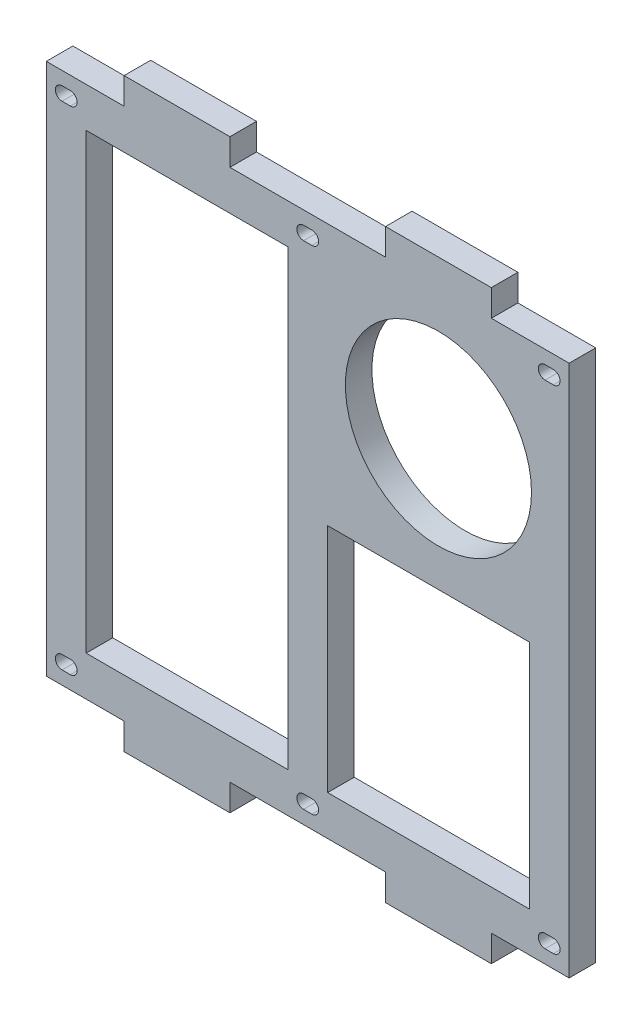
from build123d import *

# Parameters (mm, degrees)
CROQUIS1_W              = 250
CROQUIS1_H              = 280
CROQUIS1_R              = 44.5
CROQUIS1_W_2            = 96.425
CROQUIS1_H_2            = 216.5
CROQUIS1_H_3            = 110.55
SALIENTE_EXTRUIR1_DEPTH = 12.7
CROQUIS2_W              = 37.2
CROQUIS2_H              = 12.7
CROQUIS2_W_2            = 74.4
CORTAR_EXTRUIR1_DEPTH   = 13.7


with BuildPart() as part:
    # Croquis1 → Saliente-Extruir1 (new body)
    with BuildSketch(Plane.XY):
        Rectangle(CROQUIS1_W, CROQUIS1_H)
        with Locations((62.5, 64.8)):
            Circle(CROQUIS1_R, mode=Mode.SUBTRACT)
        with Locations((-57.7375, 0)):
            Rectangle(CROQUIS1_W_2, CROQUIS1_H_2, mode=Mode.SUBTRACT)
        with Locations((57.7375, -52.975)):
            Rectangle(CROQUIS1_W_2, CROQUIS1_H_3, mode=Mode.SUBTRACT)
    extrude(amount=SALIENTE_EXTRUIR1_DEPTH)

    # Croquis2 → Cortar-Extruir1 (cut, through all)
    with BuildSketch(Plane.XY.offset(12.7)):
        with Locations((-106.4, 133.65)):
            Rectangle(CROQUIS2_W, CROQUIS2_H)
        with Locations((0, 133.65)):
            Rectangle(CROQUIS2_W_2, CROQUIS2_H)
        with Locations((106.4, 133.65)):
            Rectangle(CROQUIS2_W, CROQUIS2_H)
        with BuildLine():
            Line((-117.475, 120.95), (-113.475, 120.95))
            ThreePointArc((-113.475, 120.95), (-110.275, 117.75), (-113.475, 114.55))
            Line((-113.475, 114.55), (-117.475, 114.55))
            ThreePointArc((-117.475, 114.55), (-120.675, 117.75), (-117.475, 120.95))
        make_face()
        with BuildLine():
            Line((-2, 120.95), (2, 120.95))
            ThreePointArc((2, 120.95), (5.2, 117.75), (2, 114.55))
            Line((2, 114.55), (-2, 114.55))
            ThreePointArc((-2, 114.55), (-5.2, 117.75), (-2, 120.95))
        make_face()
        with BuildLine():
            Line((113.475, 120.95), (117.475, 120.95))
            ThreePointArc((117.475, 120.95), (120.675, 117.75), (117.475, 114.55))
            Line((117.475, 114.55), (113.475, 114.55))
            ThreePointArc((113.475, 114.55), (110.275, 117.75), (113.475, 120.95))
        make_face()
    cortar_extruir1 = extrude(amount=-CORTAR_EXTRUIR1_DEPTH, mode=Mode.SUBTRACT)

    # Simetría1: Cortar-Extruir1 across plane
    add(cortar_extruir1.mirror(Plane.ZX), mode=Mode.SUBTRACT)


solid = part.part
